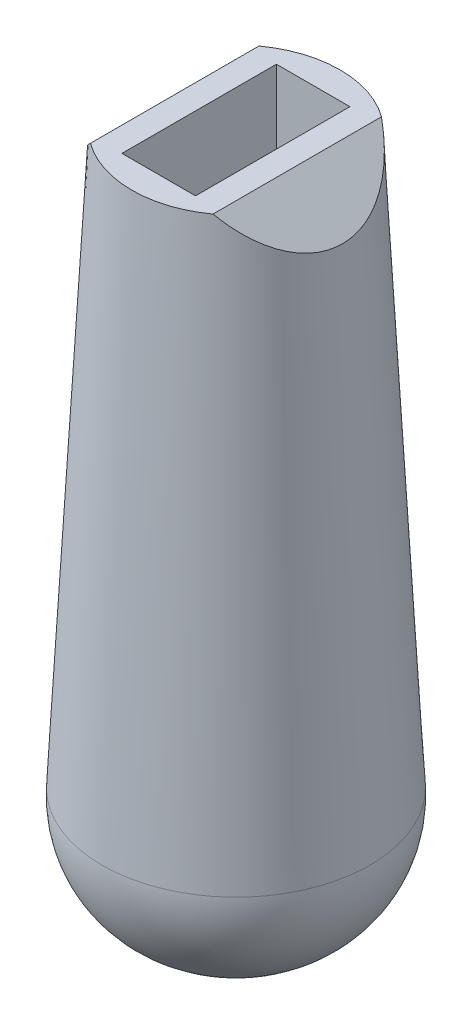
from build123d import *

# Parameters (mm, degrees)
SKETCH1_R           = 8.5
BOSS_EXTRUDE1_DEPTH = 57
BOSS_EXTRUDE1_TAPER = -3
FILLET1_R           = 10
CUT_EXTRUDE1_DEPTH  = 3
CUT_EXTRUDE2_DEPTH  = 23


with BuildPart() as part:
    # Sketch1 → Boss-Extrude1 (new body)
    with BuildSketch(Plane(origin=(0, 0, 0), x_dir=(1, 0, 0), z_dir=(0, 1, 0))):
        Circle(SKETCH1_R)
    extrude(amount=-BOSS_EXTRUDE1_DEPTH, taper=BOSS_EXTRUDE1_TAPER)

    # Fillet1
    fillet1_edges = [part.edges().sort_by_distance(p)[0] for p in [
        (-11.487243419, -57, 0),
    ]]
    fillet(fillet1_edges, radius=FILLET1_R)

    # Sketch2 → Cut-Extrude1 (cut, symmetric)
    with BuildSketch(Plane(origin=(0, 0, 0), x_dir=(0, 0, -1), z_dir=(1, 0, 0))):
        with BuildLine():
            Line((-6.3, 0), (6.3, 0))
            Line((6.3, 0), (6.3, -46.476640438))
            ThreePointArc((6.3, -46.476640438), (0, -52.776640438), (-6.3, -46.476640438))
            Line((-6.3, -46.476640438), (-6.3, 0))
        make_face()
    extrude(amount=CUT_EXTRUDE1_DEPTH, both=True, mode=Mode.SUBTRACT)

    # Sketch3 → Cut-Extrude2 (cut, symmetric)
    with BuildSketch(Plane.XY):
        Polygon((-5, 0), (5, 0), (10, -5), (10, 5), (-10, 5), (-10, -5), align=None)
    extrude(amount=CUT_EXTRUDE2_DEPTH, both=True, mode=Mode.SUBTRACT)


solid = part.part
